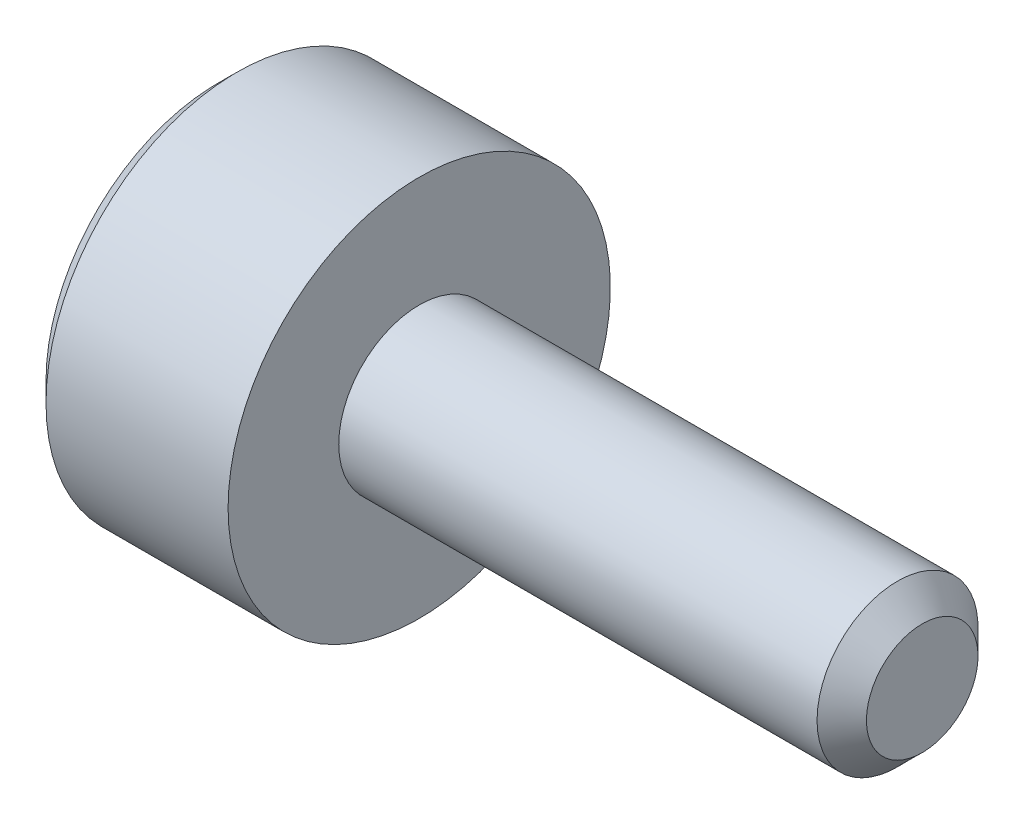
from build123d import *

# Parameters (mm, degrees)
CUT_EXTRUDE1_DEPTH = 0.8


with BuildPart() as part:
    # Sketch1 → Revolve1 (revolve)
    with BuildSketch(Plane.XY):
        Polygon((-2, 0), (-2, 1.71), (-1.81, 1.9), (0, 1.9), (0, 0.8), (4.7545, 0.8), (5, 0.5545), (5, 0), align=None)
    revolve(axis=Axis((5, 0, 0), (-1, 0, 0)))

    # Sketch2 → Cut-Extrude1 (cut)
    with BuildSketch(Plane(origin=(-2, 0, 0), x_dir=(0, 0, -1), z_dir=(1, 0, 0))):
        Polygon((-0.75, -0.433012702), (0, -0.866025404), (0.75, -0.433012702), (0.75, 0.433012702), (0, 0.866025404), (-0.75, 0.433012702), align=None)
    extrude(amount=CUT_EXTRUDE1_DEPTH, mode=Mode.SUBTRACT)


solid = part.part
